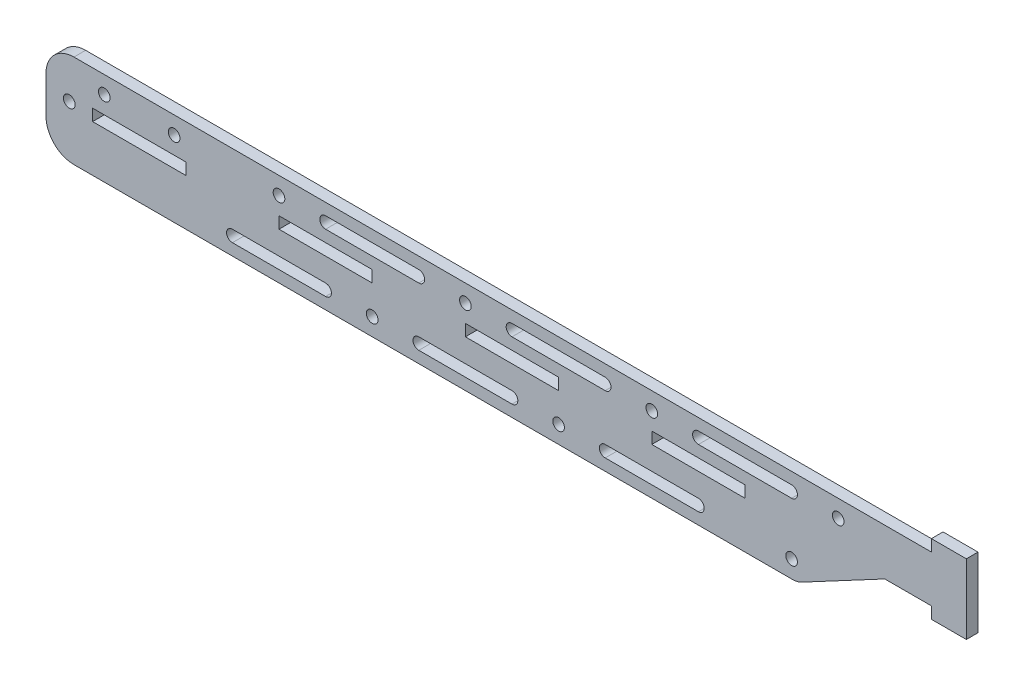
from build123d import *

# Parameters (mm, degrees)
SKETCH1_R           = 1.5875
SKETCH1_W           = 25.4
SKETCH1_H           = 3.175
BOSS_EXTRUDE1_DEPTH = 3.175


with BuildPart() as part:
    # Sketch1 → Boss-Extrude1 (new body)
    with BuildSketch(Plane.XY):
        with BuildLine():
            Line((68.764710276, 20.278973895), (56.064710276, 20.278973895))
            Line((56.064710276, 20.278973895), (33.372798511, 8.176620954))
            ThreePointArc((33.372798511, 8.176620954), (32.214291251, 7.730649994), (30.982210276, 7.578973895))
            Line((30.982210276, 7.578973895), (-152.215289724, 7.578973895))
            Line((-152.215289724, 7.578973895), (-164.915289724, 7.578973895))
            ThreePointArc((-164.915289724, 7.578973895), (-170.303443397, 9.810820222), (-172.535289724, 15.198973895))
            Line((-172.535289724, 15.198973895), (-172.535289724, 23.453973895))
            Line((-172.535289724, 23.453973895), (-172.535289724, 25.358973895))
            ThreePointArc((-172.535289724, 25.358973895), (-170.303443397, 30.747127568), (-164.915289724, 32.978973895))
            Line((-164.915289724, 32.978973895), (-152.215289724, 32.978973895))
            Line((-152.215289724, 32.978973895), (68.764710276, 32.978973895))
            Line((68.764710276, 32.978973895), (68.764710276, 36.153973895))
            Line((68.764710276, 36.153973895), (78.289710276, 36.153973895))
            Line((78.289710276, 36.153973895), (78.289710276, 17.103973895))
            Line((78.289710276, 17.103973895), (68.764710276, 17.103973895))
            Line((68.764710276, 17.103973895), (68.764710276, 20.278973895))
        make_face()
        with Locations((30.664710276, 12.341473895)):
            Circle(SKETCH1_R, mode=Mode.SUBTRACT)
        with Locations((-109.035289724, 28.216473895)):
            Circle(SKETCH1_R, mode=Mode.SUBTRACT)
        with Locations((-166.185289724, 21.866473895)):
            Circle(SKETCH1_R, mode=Mode.SUBTRACT)
        with Locations((-156.660289724, 28.216473895)):
            Circle(SKETCH1_R, mode=Mode.SUBTRACT)
        with Locations((-137.610289724, 28.216473895)):
            Circle(SKETCH1_R, mode=Mode.SUBTRACT)
        with Locations((-83.635289724, 12.341473895)):
            Circle(SKETCH1_R, mode=Mode.SUBTRACT)
        with Locations((-32.835289724, 12.341473895)):
            Circle(SKETCH1_R, mode=Mode.SUBTRACT)
        with Locations((-58.235289724, 28.216473895)):
            Circle(SKETCH1_R, mode=Mode.SUBTRACT)
        with Locations((-7.435289724, 28.216473895)):
            Circle(SKETCH1_R, mode=Mode.SUBTRACT)
        with Locations((43.364710276, 28.216473895)):
            Circle(SKETCH1_R, mode=Mode.SUBTRACT)
        with Locations((-147.135289724, 21.866473895)):
            Rectangle(SKETCH1_W, SKETCH1_H, mode=Mode.SUBTRACT)
        with Locations((-96.335289724, 21.866473895)):
            Rectangle(SKETCH1_W, SKETCH1_H, mode=Mode.SUBTRACT)
        with Locations((-45.535289724, 21.866473895)):
            Rectangle(SKETCH1_W, SKETCH1_H, mode=Mode.SUBTRACT)
        with Locations((5.264710276, 21.866473895)):
            Rectangle(SKETCH1_W, SKETCH1_H, mode=Mode.SUBTRACT)
        with BuildLine():
            Line((5.264710276, 29.803973895), (30.664710276, 29.803973895))
            ThreePointArc((30.664710276, 29.803973895), (32.252210276, 28.216473895), (30.664710276, 26.628973895))
            Line((30.664710276, 26.628973895), (5.264710276, 26.628973895))
            ThreePointArc((5.264710276, 26.628973895), (3.677210276, 28.216473895), (5.264710276, 29.803973895))
        make_face(mode=Mode.SUBTRACT)
        with BuildLine():
            Line((-45.535289724, 13.928973895), (-70.935289724, 13.928973895))
            ThreePointArc((-70.935289724, 13.928973895), (-72.522789724, 12.341473895), (-70.935289724, 10.753973895))
            Line((-70.935289724, 10.753973895), (-45.535289724, 10.753973895))
            ThreePointArc((-45.535289724, 10.753973895), (-43.947789724, 12.341473895), (-45.535289724, 13.928973895))
        make_face(mode=Mode.SUBTRACT)
        with BuildLine():
            Line((-96.335289724, 13.928973895), (-121.735289724, 13.928973895))
            ThreePointArc((-121.735289724, 13.928973895), (-123.322789724, 12.341473895), (-121.735289724, 10.753973895))
            Line((-121.735289724, 10.753973895), (-96.335289724, 10.753973895))
            ThreePointArc((-96.335289724, 10.753973895), (-94.747789724, 12.341473895), (-96.335289724, 13.928973895))
        make_face(mode=Mode.SUBTRACT)
        with BuildLine():
            Line((5.264710276, 13.928973895), (-20.135289724, 13.928973895))
            ThreePointArc((-20.135289724, 13.928973895), (-21.722789724, 12.341473895), (-20.135289724, 10.753973895))
            Line((-20.135289724, 10.753973895), (5.264710276, 10.753973895))
            ThreePointArc((5.264710276, 10.753973895), (6.852210276, 12.341473895), (5.264710276, 13.928973895))
        make_face(mode=Mode.SUBTRACT)
        with BuildLine():
            Line((-45.535289724, 29.803973895), (-20.135289724, 29.803973895))
            ThreePointArc((-20.135289724, 29.803973895), (-18.547789724, 28.216473895), (-20.135289724, 26.628973895))
            Line((-20.135289724, 26.628973895), (-45.535289724, 26.628973895))
            ThreePointArc((-45.535289724, 26.628973895), (-47.122789724, 28.216473895), (-45.535289724, 29.803973895))
        make_face(mode=Mode.SUBTRACT)
        with BuildLine():
            Line((-96.335289724, 29.803973895), (-70.935289724, 29.803973895))
            ThreePointArc((-70.935289724, 29.803973895), (-69.347789724, 28.216473895), (-70.935289724, 26.628973895))
            Line((-70.935289724, 26.628973895), (-96.335289724, 26.628973895))
            ThreePointArc((-96.335289724, 26.628973895), (-97.922789724, 28.216473895), (-96.335289724, 29.803973895))
        make_face(mode=Mode.SUBTRACT)
    extrude(amount=BOSS_EXTRUDE1_DEPTH)


solid = part.part
